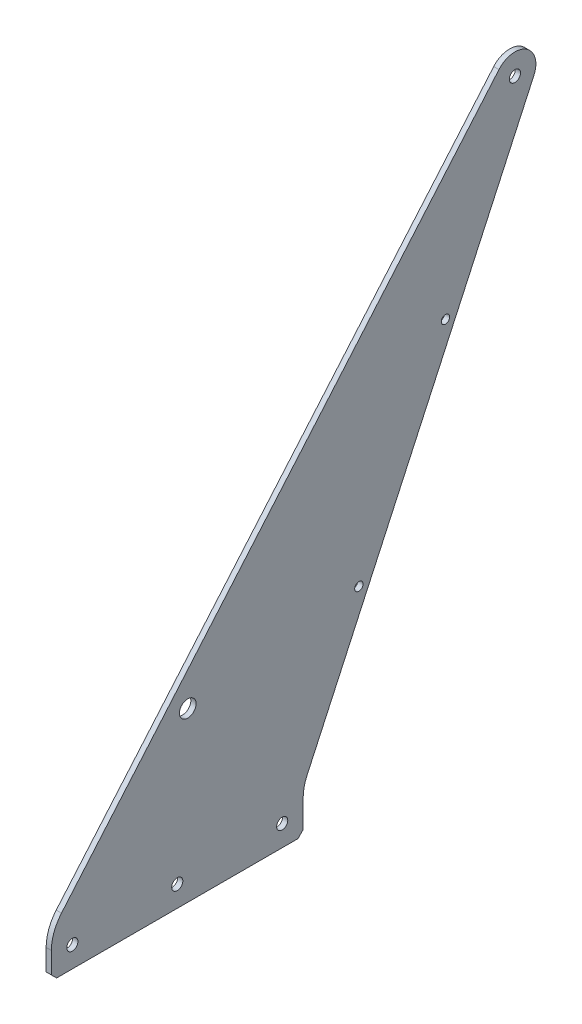
from build123d import *

# Parameters (mm, degrees)
SKETCH2_R           = 5.0419
SKETCH2_R_2         = 3.3782
BOSS_EXTRUDE2_DEPTH = 3.175
SKETCH3_R           = 3.3782
SKETCH3_R_2         = 2.54
CUT_EXTRUDE1_DEPTH  = 4.175
CHAMFER1_SIZE       = 3.175
FILLET1_R           = 25.4


with BuildPart() as part:
    # Sketch2 → Boss-Extrude2 (new body)
    with BuildSketch(Plane(origin=(0, 0, 0), x_dir=(0, 0, -1), z_dir=(1, 0, 0))):
        with BuildLine():
            Line((0, 0), (0, 25.4))
            Line((0, 25.4), (270.911778308, 342.321467673))
            ThreePointArc((270.911778308, 342.321467673), (287.412585426, 344.765407005), (292.10095893, 328.757014554))
            Line((292.10095893, 328.757014554), (152.4, 25.4))
            Line((152.4, 25.4), (152.4, 0))
            Line((152.4, 0), (0, 0))
        make_face()
        with Locations((82.55, 101.6)):
            Circle(SKETCH2_R, mode=Mode.SUBTRACT)
        with Locations((280.565394007, 334.069334376)):
            Circle(SKETCH2_R_2, mode=Mode.SUBTRACT)
    extrude(amount=BOSS_EXTRUDE2_DEPTH)

    # Sketch3 → Cut-Extrude1 (cut, through all)
    with BuildSketch(Plane(origin=(3.175, 0, 0), x_dir=(0, 0, -1), z_dir=(1, 0, 0))):
        with Locations((12.7, 12.7)):
            Circle(SKETCH3_R)
        with Locations((76.2, 12.7)):
            Circle(SKETCH3_R)
        with Locations((139.7, 12.7)):
            Circle(SKETCH3_R)
        with Locations((238.526483092, 227.602177824)):
            Circle(SKETCH3_R_2)
        with Locations((186.119185797, 113.801088912)):
            Circle(SKETCH3_R_2)
    extrude(amount=-CUT_EXTRUDE1_DEPTH, mode=Mode.SUBTRACT)

    # Chamfer1
    chamfer1_edges = [part.edges().sort_by_distance(p)[0] for p in [
        (1.5875, 0, 0),
        (1.5875, 0, -152.4),
    ]]
    chamfer(chamfer1_edges, length=CHAMFER1_SIZE)

    # Fillet1
    fillet1_edges = [part.edges().sort_by_distance(p)[0] for p in [
        (1.5875, 25.4, 0),
        (1.5875, 25.4, -152.4),
    ]]
    fillet(fillet1_edges, radius=FILLET1_R)


solid = part.part
